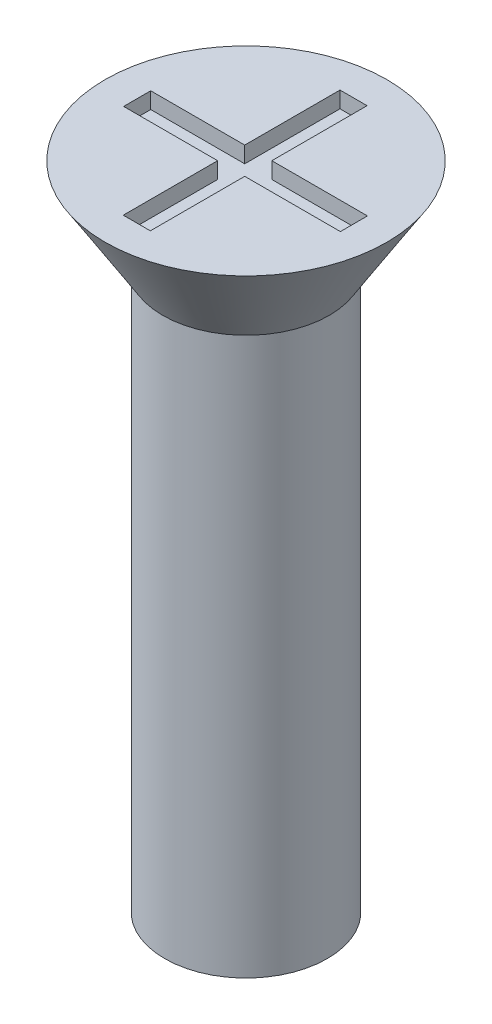
from build123d import *

# Parameters (mm, degrees)
SKETCH1_R           = 1.5
BOSS_EXTRUDE1_DEPTH = 12
SKETCH2_R           = 2.6
BOSS_EXTRUDE2_DEPTH = 1.7
BOSS_EXTRUDE2_TAPER = 32
SKETCH3_W           = 0.5
SKETCH3_H           = 1.758378485
SKETCH3_H_2         = 1.741621515
SKETCH3_W_2         = 1.734727157
SKETCH3_H_3         = 0.5
SKETCH3_W_3         = 1.765272843
CUT_EXTRUDE1_DEPTH  = 0.3


with BuildPart() as part:
    # Sketch1 → Boss-Extrude1 (new body)
    with BuildSketch(Plane(origin=(0, 0, 0), x_dir=(1, 0, 0), z_dir=(0, 1, 0))):
        Circle(SKETCH1_R)
    extrude(amount=BOSS_EXTRUDE1_DEPTH)

    # Sketch2 → Boss-Extrude2 (add)
    with BuildSketch(Plane(origin=(0, 12, 0), x_dir=(1, 0, 0), z_dir=(0, 1, 0))):
        Circle(SKETCH2_R)
    extrude(amount=-BOSS_EXTRUDE2_DEPTH, taper=BOSS_EXTRUDE2_TAPER)

    # Sketch3 → Cut-Extrude1 (cut)
    with BuildSketch(Plane(origin=(0, 12, 0), x_dir=(1, 0, 0), z_dir=(0, 1, 0))):
        with Locations((-0.015272843, 1.120810757)):
            Rectangle(SKETCH3_W, SKETCH3_H)
        with Locations((-0.015272843, -1.129189243)):
            Rectangle(SKETCH3_W, SKETCH3_H_2)
        with Locations((-1.132636421, -0.008378485)):
            Rectangle(SKETCH3_W_2, SKETCH3_H_3)
        with Locations((1.117363579, -0.008378485)):
            Rectangle(SKETCH3_W_3, SKETCH3_H_3)
        with Locations((-0.015272843, -0.008378485)):
            Rectangle(SKETCH3_W, SKETCH3_H_3)
    extrude(amount=-CUT_EXTRUDE1_DEPTH, mode=Mode.SUBTRACT)


solid = part.part
